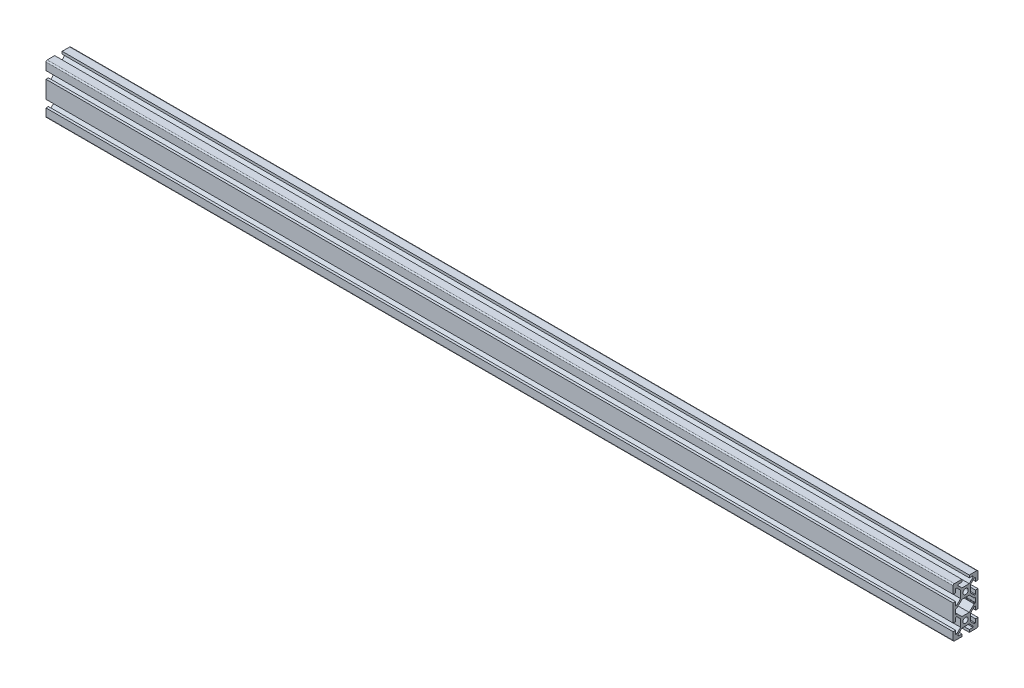
from build123d import *

# Parameters (mm, degrees)
SKETCH1_R           = 2.1
BOSS_EXTRUDE1_DEPTH = 730


with BuildPart() as part:
    # Sketch1 → Boss-Extrude1 (new body)
    with BuildSketch(Plane(origin=(0, 0, 0), x_dir=(0, 0, -1), z_dir=(1, 0, 0))):
        with BuildLine():
            Line((-10, -13), (-10, -19))
            ThreePointArc((-10, -19), (-9.707106781, -19.707106781), (-9, -20))
            Line((-9, -20), (-3, -20))
            Line((-3, -20), (-3, -18))
            Line((-3, -18), (-6, -18))
            Line((-6, -18), (-6, -17.060660172))
            Line((-6, -17.060660172), (-2.939339828, -14))
            Line((-2.939339828, -14), (2.939339828, -14))
            Line((2.939339828, -14), (6, -17.060660172))
            Line((6, -17.060660172), (6, -18))
            Line((6, -18), (3, -18))
            Line((3, -18), (3, -20))
            Line((3, -20), (9, -20))
            ThreePointArc((9, -20), (9.707106781, -19.707106781), (10, -19))
            Line((10, -19), (10, -13))
            Line((10, -13), (8, -13))
            Line((8, -13), (8, -16))
            Line((8, -16), (7.060660172, -16))
            Line((7.060660172, -16), (4, -12.939339828))
            Line((4, -12.939339828), (4, -7.060660172))
            Line((4, -7.060660172), (7.060660172, -4))
            Line((7.060660172, -4), (8, -4))
            Line((8, -4), (8, -7))
            Line((8, -7), (10, -7))
            Line((10, -7), (10, 7))
            Line((10, 7), (8, 7))
            Line((8, 7), (8, 4))
            Line((8, 4), (7.060660172, 4))
            Line((7.060660172, 4), (4, 7.060660172))
            Line((4, 7.060660172), (4, 12.939339828))
            Line((4, 12.939339828), (7.060660172, 16))
            Line((7.060660172, 16), (8, 16))
            Line((8, 16), (8, 13))
            Line((8, 13), (10, 13))
            Line((10, 13), (10, 19))
            ThreePointArc((10, 19), (9.707106781, 19.707106781), (9, 20))
            Line((9, 20), (3, 20))
            Line((3, 20), (3, 18))
            Line((3, 18), (6, 18))
            Line((6, 18), (6, 17.060660172))
            Line((6, 17.060660172), (2.939339828, 14))
            Line((2.939339828, 14), (-2.939339828, 14))
            Line((-2.939339828, 14), (-6, 17.060660172))
            Line((-6, 17.060660172), (-6, 18))
            Line((-6, 18), (-3, 18))
            Line((-3, 18), (-3, 20))
            Line((-3, 20), (-9, 20))
            ThreePointArc((-9, 20), (-9.707106781, 19.707106781), (-10, 19))
            Line((-10, 19), (-10, 13))
            Line((-10, 13), (-8, 13))
            Line((-8, 13), (-8, 16))
            Line((-8, 16), (-7.060660172, 16))
            Line((-7.060660172, 16), (-4, 12.939339828))
            Line((-4, 12.939339828), (-4, 7.060660172))
            Line((-4, 7.060660172), (-7.060660172, 4))
            Line((-7.060660172, 4), (-8, 4))
            Line((-8, 4), (-8, 7))
            Line((-8, 7), (-10, 7))
            Line((-10, 7), (-10, -7))
            Line((-10, -7), (-8, -7))
            Line((-8, -7), (-8, -4))
            Line((-8, -4), (-7.060660172, -4))
            Line((-7.060660172, -4), (-4, -7.060660172))
            Line((-4, -7.060660172), (-4, -12.939339828))
            Line((-4, -12.939339828), (-7.060660172, -16))
            Line((-7.060660172, -16), (-8, -16))
            Line((-8, -16), (-8, -13))
            Line((-8, -13), (-10, -13))
        make_face()
        with Locations((0, 10)):
            Circle(SKETCH1_R, mode=Mode.SUBTRACT)
        with Locations((0, -10)):
            Circle(SKETCH1_R, mode=Mode.SUBTRACT)
        with BuildLine():
            Line((-8, 1.7), (-8, -1.7))
            ThreePointArc((-8, -1.7), (-7.912132034, -1.912132034), (-7.7, -2))
            Line((-7.7, -2), (-7.063603897, -2))
            ThreePointArc((-7.063603897, -2), (-6.948798867, -2.02283614), (-6.851471863, -2.087867966))
            Line((-6.851471863, -2.087867966), (-2.939339828, -6))
            Line((-2.939339828, -6), (2.939339828, -6))
            Line((2.939339828, -6), (6.851471863, -2.087867966))
            ThreePointArc((6.851471863, -2.087867966), (6.948798867, -2.02283614), (7.063603897, -2))
            Line((7.063603897, -2), (7.7, -2))
            ThreePointArc((7.7, -2), (7.912132034, -1.912132034), (8, -1.7))
            Line((8, -1.7), (8, 1.7))
            ThreePointArc((8, 1.7), (7.912132034, 1.912132034), (7.7, 2))
            Line((7.7, 2), (7.063603897, 2))
            ThreePointArc((7.063603897, 2), (6.948798867, 2.02283614), (6.851471863, 2.087867966))
            Line((6.851471863, 2.087867966), (2.939339828, 6))
            Line((2.939339828, 6), (-2.939339828, 6))
            Line((-2.939339828, 6), (-6.851471863, 2.087867966))
            ThreePointArc((-6.851471863, 2.087867966), (-6.948798867, 2.02283614), (-7.063603897, 2))
            Line((-7.063603897, 2), (-7.7, 2))
            ThreePointArc((-7.7, 2), (-7.912132034, 1.912132034), (-8, 1.7))
        make_face(mode=Mode.SUBTRACT)
    extrude(amount=BOSS_EXTRUDE1_DEPTH)


solid = part.part
